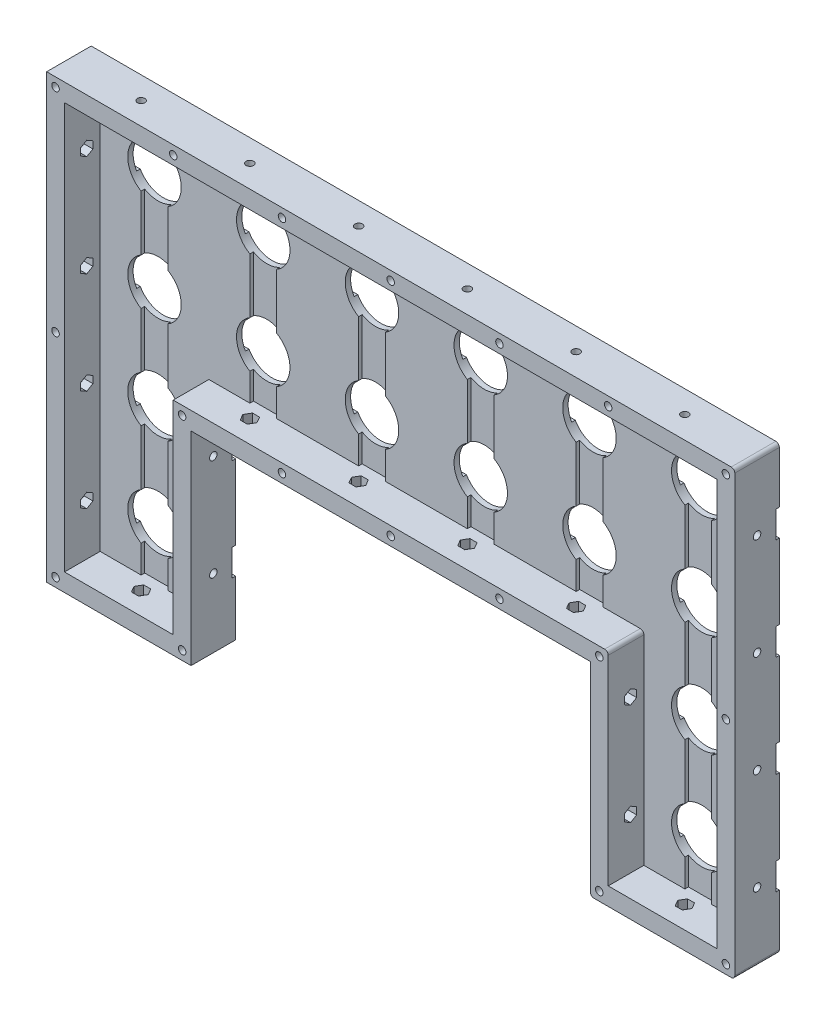
from build123d import *

# Parameters (mm, degrees)
SALIENTE_EXTRUIR1_DEPTH = 25
CORTAR_EXTRUIR1_DEPTH   = 20
CROQUIS3_R              = 15
CORTAR_EXTRUIR2_DEPTH   = 6
CROQUIS4_W              = 2
CROQUIS4_H              = 15
CORTAR_EXTRUIR3_DEPTH   = 387
CROQUIS5_W              = 15
CROQUIS5_H              = 228
CROQUIS5_H_2            = 114
CORTAR_EXTRUIR4_DEPTH   = 2
CROQUIS6_R              = 2.1
CORTAR_EXTRUIR5_DEPTH   = 249
CORTAR_EXTRUIR6_DEPTH   = 5
CORTAR_EXTRUIR7_DEPTH   = 5
CORTAR_EXTRUIR8_DEPTH   = 5
CROQUIS11_R             = 2.1
CORTAR_EXTRUIR9_DEPTH   = 387
CORTAR_EXTRUIR10_DEPTH  = 5
CORTAR_EXTRUIR11_DEPTH  = 5
CORTAR_EXTRUIR12_DEPTH  = 5
CORTAR_EXTRUIR13_DEPTH  = 5
CROQUIS16_R             = 2.1
CORTAR_EXTRUIR14_DEPTH  = 26
CORTAR_EXTRUIR15_DEPTH  = 10
REDONDEO1_R             = 2


with BuildPart() as part:
    # Croquis1 → Saliente-Extruir1 (new body)
    with BuildSketch(Plane.XY):
        Polygon((-193, -124), (-193, 124), (193, 124), (193, -124), (112, -124), (112, -10), (-112, -10), (-112, -124), align=None)
    extrude(amount=SALIENTE_EXTRUIR1_DEPTH)

    # Croquis2 → Cortar-Extruir1 (cut)
    with BuildSketch(Plane.XY.offset(25)):
        Polygon((-183, 114), (183, 114), (183, -114), (122, -114), (122, 0), (-122, 0), (-122, -114), (-183, -114), align=None)
    extrude(amount=-CORTAR_EXTRUIR1_DEPTH, mode=Mode.SUBTRACT)

    # Croquis3 → Cortar-Extruir2 (cut, through all)
    with BuildSketch(Plane.XY.offset(5)):
        with Locations((30.5, 85.5)):
            Circle(CROQUIS3_R)
        with Locations((91.5, 85.5)):
            Circle(CROQUIS3_R)
        with Locations((152.5, 85.5)):
            Circle(CROQUIS3_R)
        with Locations((91.5, 28.5)):
            Circle(CROQUIS3_R)
        with Locations((152.5, 28.5)):
            Circle(CROQUIS3_R)
        with Locations((152.5, -28.5)):
            Circle(CROQUIS3_R)
        with Locations((152.5, -85.5)):
            Circle(CROQUIS3_R)
        with Locations((30.5, 28.5)):
            Circle(CROQUIS3_R)
    cortar_extruir2 = extrude(amount=-CORTAR_EXTRUIR2_DEPTH, mode=Mode.SUBTRACT)

    # Simetría3: Cortar-Extruir2 across plane
    add(cortar_extruir2.mirror(Plane(origin=(0, 0, 0), x_dir=(0, 0, 1), z_dir=(1, 0, 0))), mode=Mode.SUBTRACT)

    # Croquis4 → Cortar-Extruir3 (cut, through all)
    with BuildSketch(Plane(origin=(193, 0, 0), x_dir=(0, 0, -1), z_dir=(1, 0, 0))):
        with Locations((-1, 85.5)):
            Rectangle(CROQUIS4_W, CROQUIS4_H)
        with Locations((-1, 28.5)):
            Rectangle(CROQUIS4_W, CROQUIS4_H)
        with Locations((-1, -28.5)):
            Rectangle(CROQUIS4_W, CROQUIS4_H)
        with Locations((-1, -85.5)):
            Rectangle(CROQUIS4_W, CROQUIS4_H)
    extrude(amount=-CORTAR_EXTRUIR3_DEPTH, mode=Mode.SUBTRACT)

    # Croquis5 → Cortar-Extruir4 (cut)
    with BuildSketch(Plane.XY.offset(5)):
        with Locations((-152.5, 0)):
            Rectangle(CROQUIS5_W, CROQUIS5_H)
        with Locations((-91.5, 57)):
            Rectangle(CROQUIS5_W, CROQUIS5_H_2)
        with Locations((-30.5, 57)):
            Rectangle(CROQUIS5_W, CROQUIS5_H_2)
    cortar_extruir4 = extrude(amount=-CORTAR_EXTRUIR4_DEPTH, mode=Mode.SUBTRACT)

    # Simetría4: Cortar-Extruir4 across plane
    add(cortar_extruir4.mirror(Plane(origin=(0, 0, 0), x_dir=(0, 0, 1), z_dir=(1, 0, 0))), mode=Mode.SUBTRACT)

    # Croquis6 → Cortar-Extruir5 (cut, through all)
    with BuildSketch(Plane(origin=(0, 124, 0), x_dir=(1, 0, 0), z_dir=(0, 1, 0))):
        with Locations((30.5, -12.5)):
            Circle(CROQUIS6_R)
        with Locations((91.5, -12.5)):
            Circle(CROQUIS6_R)
        with Locations((152.5, -12.5)):
            Circle(CROQUIS6_R)
    cortar_extruir5 = extrude(amount=-CORTAR_EXTRUIR5_DEPTH, mode=Mode.SUBTRACT)

    # Croquis7 → Cortar-Extruir6 (cut)
    with BuildSketch(Plane.XZ.offset(-114)):
        Polygon((34.483716857, 12.5), (32.491858429, 15.95), (28.508141571, 15.95), (26.516283143, 12.5), (28.508141571, 9.05), (32.491858429, 9.05), align=None)
        Polygon((95.483716857, 12.5), (93.491858429, 15.95), (89.508141571, 15.95), (87.516283143, 12.5), (89.508141571, 9.05), (93.491858429, 9.05), align=None)
        Polygon((156.483716857, 12.5), (154.491858429, 15.95), (150.508141571, 15.95), (148.516283143, 12.5), (150.508141571, 9.05), (154.491858429, 9.05), align=None)
    cortar_extruir6 = extrude(amount=-CORTAR_EXTRUIR6_DEPTH, mode=Mode.SUBTRACT)

    # Croquis9 → Cortar-Extruir7 (cut)
    with BuildSketch(Plane(origin=(0, 0, 0), x_dir=(1, 0, 0), z_dir=(0, 1, 0))):
        Polygon((34.483716857, -12.5), (32.491858429, -9.05), (28.508141571, -9.05), (26.516283143, -12.5), (28.508141571, -15.95), (32.491858429, -15.95), align=None)
        Polygon((95.483716857, -12.5), (93.491858429, -9.05), (89.508141571, -9.05), (87.516283143, -12.5), (89.508141571, -15.95), (93.491858429, -15.95), align=None)
    cortar_extruir7 = extrude(amount=-CORTAR_EXTRUIR7_DEPTH, mode=Mode.SUBTRACT)

    # Croquis10 → Cortar-Extruir8 (cut)
    with BuildSketch(Plane(origin=(0, -114, 0), x_dir=(1, 0, 0), z_dir=(0, 1, 0))):
        Polygon((156.483716857, -12.5), (154.491858429, -9.05), (150.508141571, -9.05), (148.516283143, -12.5), (150.508141571, -15.95), (154.491858429, -15.95), align=None)
    cortar_extruir8 = extrude(amount=-CORTAR_EXTRUIR8_DEPTH, mode=Mode.SUBTRACT)

    # Simetría5: Cortar-Extruir5, Cortar-Extruir6, Cortar-Extruir7, Cortar-Extruir8 across plane
    add(cortar_extruir5.mirror(Plane(origin=(0, 0, 0), x_dir=(0, 0, 1), z_dir=(1, 0, 0))), mode=Mode.SUBTRACT)
    add(cortar_extruir6.mirror(Plane(origin=(0, 0, 0), x_dir=(0, 0, 1), z_dir=(1, 0, 0))), mode=Mode.SUBTRACT)
    add(cortar_extruir7.mirror(Plane(origin=(0, 0, 0), x_dir=(0, 0, 1), z_dir=(1, 0, 0))), mode=Mode.SUBTRACT)
    add(cortar_extruir8.mirror(Plane(origin=(0, 0, 0), x_dir=(0, 0, 1), z_dir=(1, 0, 0))), mode=Mode.SUBTRACT)

    # Croquis11 → Cortar-Extruir9 (cut, through all)
    with BuildSketch(Plane.ZY.offset(193)):
        with Locations((12.5, 85.5)):
            Circle(CROQUIS11_R)
        with Locations((12.5, 28.5)):
            Circle(CROQUIS11_R)
        with Locations((12.5, -28.5)):
            Circle(CROQUIS11_R)
        with Locations((12.5, -85.5)):
            Circle(CROQUIS11_R)
    extrude(amount=-CORTAR_EXTRUIR9_DEPTH, mode=Mode.SUBTRACT)

    # Croquis12 → Cortar-Extruir10 (cut)
    with BuildSketch(Plane(origin=(-183, 0, 0), x_dir=(0, 0, -1), z_dir=(1, 0, 0))):
        Polygon((-12.5, 81.516283143), (-9.05, 83.508141571), (-9.05, 87.491858429), (-12.5, 89.483716857), (-15.95, 87.491858429), (-15.95, 83.508141571), align=None)
        Polygon((-12.5, 24.516283143), (-9.05, 26.508141571), (-9.05, 30.491858429), (-12.5, 32.483716857), (-15.95, 30.491858429), (-15.95, 26.508141571), align=None)
        Polygon((-12.5, -32.483716857), (-9.05, -30.491858429), (-9.05, -26.508141571), (-12.5, -24.516283143), (-15.95, -26.508141571), (-15.95, -30.491858429), align=None)
        Polygon((-12.5, -89.483716857), (-9.05, -87.491858429), (-9.05, -83.508141571), (-12.5, -81.516283143), (-15.95, -83.508141571), (-15.95, -87.491858429), align=None)
    extrude(amount=-CORTAR_EXTRUIR10_DEPTH, mode=Mode.SUBTRACT)

    # Croquis13 → Cortar-Extruir11 (cut)
    with BuildSketch(Plane.ZY.offset(-183)):
        Polygon((12.5, 24.516283143), (15.95, 26.508141571), (15.95, 30.491858429), (12.5, 32.483716857), (9.05, 30.491858429), (9.05, 26.508141571), align=None)
        Polygon((12.5, 81.516283143), (15.95, 83.508141571), (15.95, 87.491858429), (12.5, 89.483716857), (9.05, 87.491858429), (9.05, 83.508141571), align=None)
        Polygon((12.5, -32.483716857), (15.95, -30.491858429), (15.95, -26.508141571), (12.5, -24.516283143), (9.05, -26.508141571), (9.05, -30.491858429), align=None)
        Polygon((12.5, -89.483716857), (15.95, -87.491858429), (15.95, -83.508141571), (12.5, -81.516283143), (9.05, -83.508141571), (9.05, -87.491858429), align=None)
    extrude(amount=-CORTAR_EXTRUIR11_DEPTH, mode=Mode.SUBTRACT)

    # Croquis14 → Cortar-Extruir12 (cut)
    with BuildSketch(Plane(origin=(122, 0, 0), x_dir=(0, 0, -1), z_dir=(1, 0, 0))):
        Polygon((-12.5, -81.516283143), (-15.95, -83.508141571), (-15.95, -87.491858429), (-12.5, -89.483716857), (-9.05, -87.491858429), (-9.05, -83.508141571), align=None)
        Polygon((-12.5, -24.516283143), (-15.95, -26.508141571), (-15.95, -30.491858429), (-12.5, -32.483716857), (-9.05, -30.491858429), (-9.05, -26.508141571), align=None)
    extrude(amount=-CORTAR_EXTRUIR12_DEPTH, mode=Mode.SUBTRACT)

    # Croquis15 → Cortar-Extruir13 (cut)
    with BuildSketch(Plane.ZY.offset(122)):
        Polygon((12.5, -81.516283143), (9.05, -83.508141571), (9.05, -87.491858429), (12.5, -89.483716857), (15.95, -87.491858429), (15.95, -83.508141571), align=None)
        Polygon((12.5, -24.516283143), (9.05, -26.508141571), (9.05, -30.491858429), (12.5, -32.483716857), (15.95, -30.491858429), (15.95, -26.508141571), align=None)
    extrude(amount=-CORTAR_EXTRUIR13_DEPTH, mode=Mode.SUBTRACT)

    # Croquis16 → Cortar-Extruir14 (cut, through all)
    with BuildSketch(Plane.XY.offset(25)):
        with Locations((-188, 119)):
            Circle(CROQUIS16_R)
        with Locations((-122, 119)):
            Circle(CROQUIS16_R)
        with Locations((-61, 119)):
            Circle(CROQUIS16_R)
        with Locations((0, 119)):
            Circle(CROQUIS16_R)
        with Locations((188, 119)):
            Circle(CROQUIS16_R)
        with Locations((122, 119)):
            Circle(CROQUIS16_R)
        with Locations((61, 119)):
            Circle(CROQUIS16_R)
        with Locations((61, -5)):
            Circle(CROQUIS16_R)
        with Locations((0, -5)):
            Circle(CROQUIS16_R)
        with Locations((-61, -5)):
            Circle(CROQUIS16_R)
        with Locations((188, -119)):
            Circle(CROQUIS16_R)
        with Locations((-188, -119)):
            Circle(CROQUIS16_R)
        with Locations((-188, 0)):
            Circle(CROQUIS16_R)
        with Locations((188, 0)):
            Circle(CROQUIS16_R)
        with Locations((-117, -119)):
            Circle(CROQUIS16_R)
        with Locations((-117, -5)):
            Circle(CROQUIS16_R)
        with Locations((117, -5)):
            Circle(CROQUIS16_R)
        with Locations((117, -119)):
            Circle(CROQUIS16_R)
    extrude(amount=-CORTAR_EXTRUIR14_DEPTH, mode=Mode.SUBTRACT)

    # Croquis17 → Cortar-Extruir15 (cut)
    with BuildSketch(Plane(origin=(0, 0, 0), x_dir=(-1, 0, 0), z_dir=(0, 0, -1))):
        Polygon((-184.016283143, 119), (-186.008141571, 122.45), (-189.991858429, 122.45), (-191.983716857, 119), (-189.991858429, 115.55), (-186.008141571, 115.55), align=None)
        Polygon((-118.016283143, 119), (-120.008141571, 122.45), (-123.991858429, 122.45), (-125.983716857, 119), (-123.991858429, 115.55), (-120.008141571, 115.55), align=None)
        Polygon((-57.016283143, 119), (-59.008141571, 122.45), (-62.991858429, 122.45), (-64.983716857, 119), (-62.991858429, 115.55), (-59.008141571, 115.55), align=None)
        Polygon((4.436751934, 119), (2.218375967, 122.842339885), (-2.218375967, 122.842339885), (-4.436751934, 119), (-2.218375967, 115.157660115), (2.218375967, 115.157660115), align=None)
        Polygon((65.909950654, 119), (63.454975327, 123.252141997), (58.545024673, 123.252141997), (56.090049346, 119), (58.545024673, 114.747858003), (63.454975327, 114.747858003), align=None)
        Polygon((126.819125066, 119), (124.409562533, 123.173484732), (119.590437467, 123.173484732), (117.180874934, 119), (119.590437467, 114.826515268), (124.409562533, 114.826515268), align=None)
        Polygon((191.773893683, 119), (189.883473616, 122.274303605), (186.102633481, 122.274303605), (184.212213413, 119), (186.102633481, 115.725696395), (189.883473616, 115.725696395), align=None)
        Polygon((191.983716857, 0), (189.991858429, 3.45), (186.008141571, 3.45), (184.016283143, 0), (186.008141571, -3.45), (189.991858429, -3.45), align=None)
        Polygon((191.983716857, -119), (189.991858429, -115.55), (186.008141571, -115.55), (184.016283143, -119), (186.008141571, -122.45), (189.991858429, -122.45), align=None)
        Polygon((120.983716857, -119), (118.991858429, -115.55), (115.008141571, -115.55), (113.016283143, -119), (115.008141571, -122.45), (118.991858429, -122.45), align=None)
        Polygon((120.983716857, -5), (118.991858429, -1.55), (115.008141571, -1.55), (113.016283143, -5), (115.008141571, -8.45), (118.991858429, -8.45), align=None)
        Polygon((64.983716857, -5), (62.991858429, -1.55), (59.008141571, -1.55), (57.016283143, -5), (59.008141571, -8.45), (62.991858429, -8.45), align=None)
        Polygon((-57.016283143, -5), (-59.008141571, -1.55), (-62.991858429, -1.55), (-64.983716857, -5), (-62.991858429, -8.45), (-59.008141571, -8.45), align=None)
        Polygon((3.983716857, -5), (1.991858429, -1.55), (-1.991858429, -1.55), (-3.983716857, -5), (-1.991858429, -8.45), (1.991858429, -8.45), align=None)
        Polygon((-113.016283143, -5), (-115.008141571, -1.55), (-118.991858429, -1.55), (-120.983716857, -5), (-118.991858429, -8.45), (-115.008141571, -8.45), align=None)
        Polygon((-184.016283143, 0), (-186.008141571, 3.45), (-189.991858429, 3.45), (-191.983716857, 0), (-189.991858429, -3.45), (-186.008141571, -3.45), align=None)
        Polygon((-184.016283143, -119), (-186.008141571, -115.55), (-189.991858429, -115.55), (-191.983716857, -119), (-189.991858429, -122.45), (-186.008141571, -122.45), align=None)
        Polygon((-113.016283143, -119), (-115.008141571, -115.55), (-118.991858429, -115.55), (-120.983716857, -119), (-118.991858429, -122.45), (-115.008141571, -122.45), align=None)
    extrude(amount=-CORTAR_EXTRUIR15_DEPTH, mode=Mode.SUBTRACT)

    # Redondeo1
    redondeo1_edges = [part.edges().sort_by_distance(p)[0] for p in [
        (193, -124, 12.5),
        (112, -124, 12.5),
        (193, 124, 12.5),
        (122, 0, 15),
    ]]
    fillet(redondeo1_edges, radius=REDONDEO1_R)


solid = part.part
